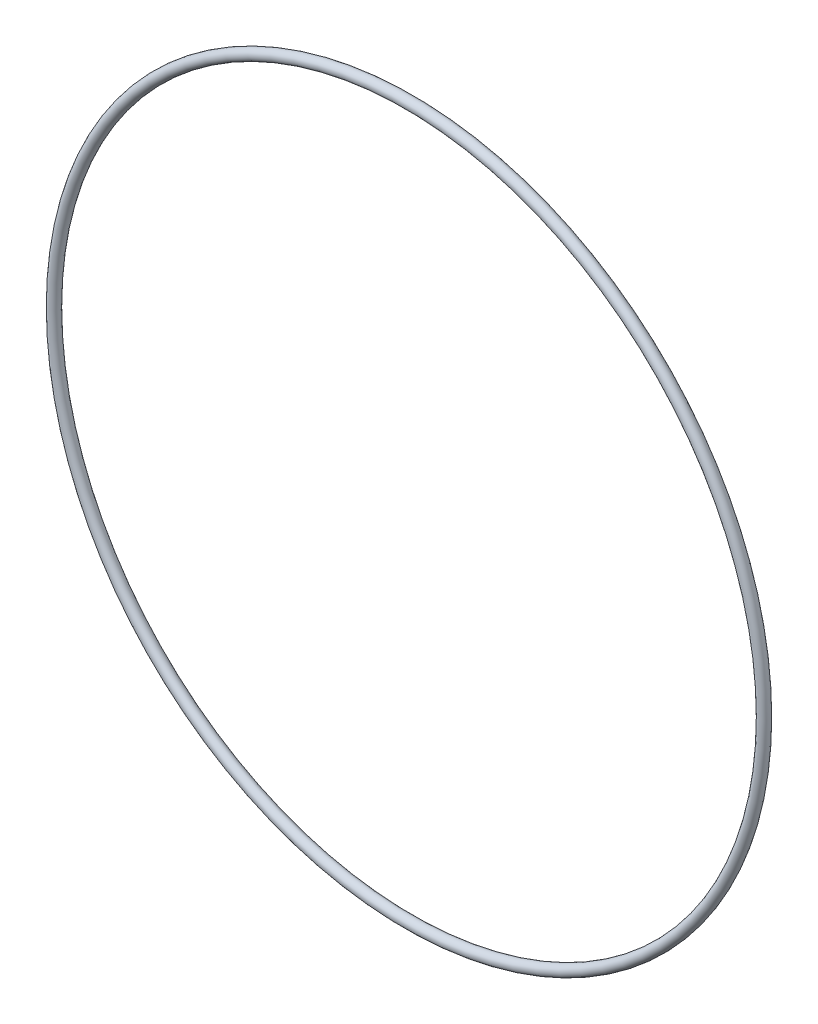
from build123d import *

# Parameters (mm, degrees)
SKETCH1_R = 0.889


with BuildPart() as part:
    # Sketch1 → Revolve1 (revolve)
    with BuildSketch(Plane(origin=(0, 0, 0), x_dir=(0, -1, 0), z_dir=(1, 0, 0))):
        with Locations((57.8993, 0)):
            Circle(SKETCH1_R)
    revolve(axis=Axis((0, 0, 0.889), (0, 0, -1)))


solid = part.part
